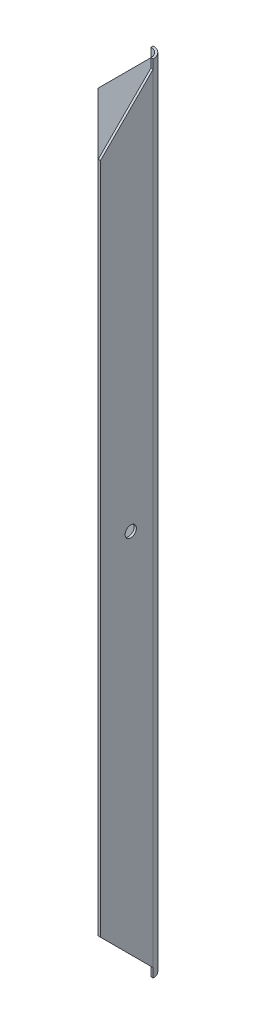
from build123d import *

# Parameters (mm, degrees)
BOSS_EXTRUDE1_DEPTH            = 2
BOSS_EXTRUDE3_DEPTH            = 2
CUT_EXTRUDE2_REACH             = 365.729
CUT_EXTRUDE2_DIRECTION_2_REACH = 365.729
BOSS_EXTRUDE5_DEPTH            = 355
BOSS_EXTRUDE5_DEPTH_BACK       = 355
SKETCH7_R                      = 5
CUT_EXTRUDE3_DEPTH             = 355
SKETCH8_R                      = 5
CUT_EXTRUDE4_DEPTH             = 355


with BuildPart() as part:
    # Sketch1 → Boss-Extrude1 (new body)
    with BuildSketch(Plane(origin=(0, 0, 0), x_dir=(0, 0, -1), z_dir=(1, 0, 0))):
        Polygon((0, -300), (55, -355), (57, -355), (57, 355), (55, 355), (0, 300), align=None)
    extrude(amount=BOSS_EXTRUDE1_DEPTH)

    # Sketch2 → Boss-Extrude3 (add)
    with BuildSketch(Plane(origin=(0, 0, -57), x_dir=(-1, 0, 0), z_dir=(0, 0, -1))):
        Polygon((55, 300), (55, -300), (0, -355), (0, 355), align=None)
    extrude(amount=-BOSS_EXTRUDE3_DEPTH)

    # Sketch3 → Cut-Extrude2 (cut, up to next)
    with BuildSketch(Plane(origin=(0, 0, 0), x_dir=(-1, 0, 0), z_dir=(0, -1, 0)), mode=Mode.PRIVATE) as cut_extrude2_sk1:
        with BuildLine():
            Line((8, 57), (-2, 57))
            Line((-2, 57), (-2, 47))
            ThreePointArc((-2, 47), (0.928932188, 54.071067812), (8, 57))
        make_face()
    cut_extrude2_tool1 = extrude(cut_extrude2_sk1.sketch, amount=-CUT_EXTRUDE2_REACH, mode=Mode.PRIVATE) & part.part
    add(cut_extrude2_tool1.solids().sort_by_distance((-0.233679, 0, -54.766321))[0], mode=Mode.SUBTRACT)

    # Sketch3 → Cut-Extrude2 direction 2 (cut, up to next)
    with BuildSketch(Plane(origin=(0, 0, 0), x_dir=(-1, 0, 0), z_dir=(0, -1, 0)), mode=Mode.PRIVATE) as cut_extrude2_direction_2_sk1:
        with BuildLine():
            Line((8, 57), (-2, 57))
            Line((-2, 57), (-2, 47))
            ThreePointArc((-2, 47), (0.928932188, 54.071067812), (8, 57))
        make_face()
    cut_extrude2_direction_2_tool1 = extrude(cut_extrude2_direction_2_sk1.sketch, amount=CUT_EXTRUDE2_DIRECTION_2_REACH, mode=Mode.PRIVATE) & part.part
    add(cut_extrude2_direction_2_tool1.solids().sort_by_distance((-0.233679, 0, -54.766321))[0], mode=Mode.SUBTRACT)


with BuildPart() as cut_extrude2_piece_1:
    # of the separate pieces the step leaves, piece 1, a body of its own (cut_extrude2_pieces)
    add(part.part.solids().sort_by_distance((-8, -347, -57))[0])



with BuildPart() as cut_extrude2_piece_2:
    # of the separate pieces the step leaves, piece 2, a body of its own (cut_extrude2_pieces)
    add(part.part.solids().sort_by_distance((0, 300, 0))[0])


with BuildPart() as cut_extrude2_piece_1_1:
    add(cut_extrude2_piece_1.part)

    add(cut_extrude2_piece_2.part)  # Boss-Extrude5 merges Cut-Extrude2 piece 2
    # Sketch6 → Boss-Extrude5 (add, two sides: drawn at the far end of the back side and taken through both)
    with BuildSketch(Plane(origin=(0, 0, 0), x_dir=(-1, 0, 0), z_dir=(0, -1, 0)).offset(-BOSS_EXTRUDE5_DEPTH_BACK)):
        with BuildLine():
            Line((8, 55), (8, 57))
            ThreePointArc((8, 57), (0.928932188, 54.071067812), (-2, 47))
            Line((-2, 47), (0, 47))
            ThreePointArc((0, 47), (2.343145751, 52.656854249), (8, 55))
        make_face()
    extrude(amount=BOSS_EXTRUDE5_DEPTH + BOSS_EXTRUDE5_DEPTH_BACK)

    # Sketch7 → Cut-Extrude3 (cut)
    with BuildSketch(Plane(origin=(0, 0, -57), x_dir=(-1, 0, 0), z_dir=(0, 0, -1))):
        with Locations((28, 0)):
            Circle(SKETCH7_R)
    extrude(amount=-CUT_EXTRUDE3_DEPTH, mode=Mode.SUBTRACT)

    # Sketch8 → Cut-Extrude4 (cut)
    with BuildSketch(Plane(origin=(2, 0, 0), x_dir=(0, 0, -1), z_dir=(1, 0, 0))):
        with Locations((27, 0)):
            Circle(SKETCH8_R)
    extrude(amount=-CUT_EXTRUDE4_DEPTH, mode=Mode.SUBTRACT)


solid = cut_extrude2_piece_1_1.part
